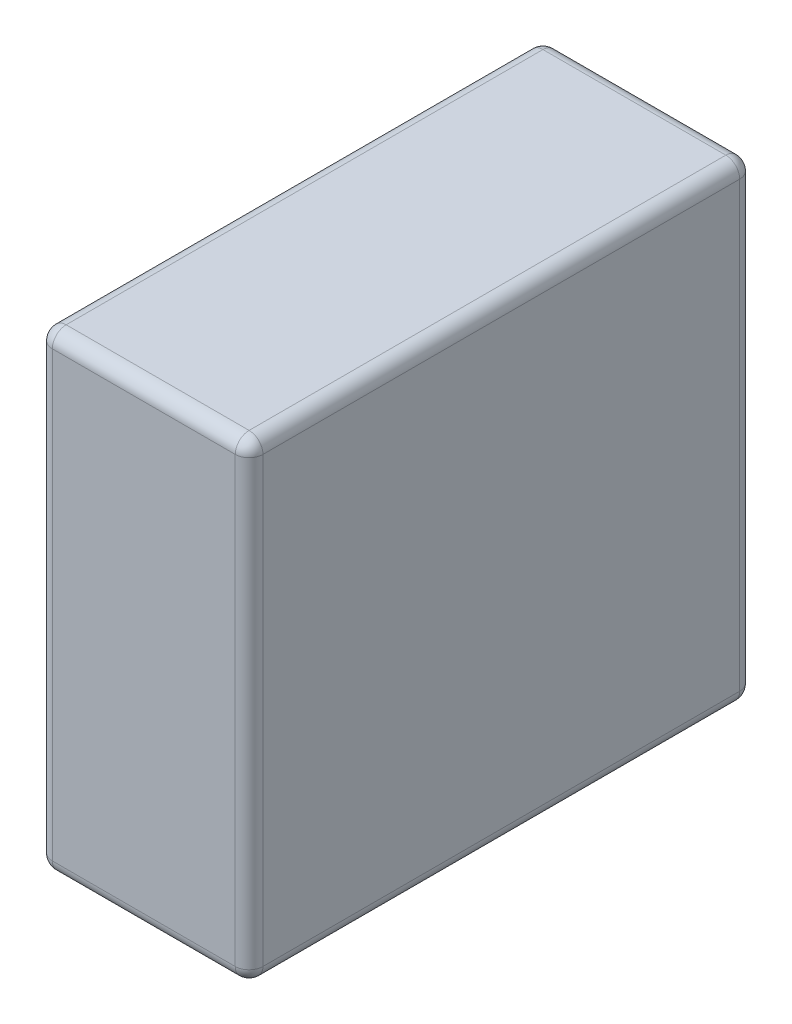
from build123d import *

# Parameters (mm, degrees)
SKETCH_1_W      = 76
SKETCH_1_H      = 182
EXTRUDE_1_DEPTH = 170
FILLET_1_R      = 5


with BuildPart() as part:
    # Эскиз1 → Бобышка-Вытянуть1 (new body)
    with BuildSketch(Plane(origin=(0, 0, 0), x_dir=(1, 0, 0), z_dir=(0, 1, 0))):
        Rectangle(SKETCH_1_W, SKETCH_1_H)
    extrude(amount=EXTRUDE_1_DEPTH)

    # Скругление1
    fillet_1_edges = [part.edges().sort_by_distance(p)[0] for p in [
        (38, 170, 0),
        (0, 170, -91),
        (-38, 170, 0),
        (0, 0, -91),
        (38, 0, 0),
        (0, 0, 91),
        (-38, 0, 0),
        (0, 170, 91),
        (-38, 85, -91),
        (38, 85, -91),
        (38, 85, 91),
        (-38, 85, 91),
    ]]
    fillet(fillet_1_edges, radius=FILLET_1_R)


solid = part.part
